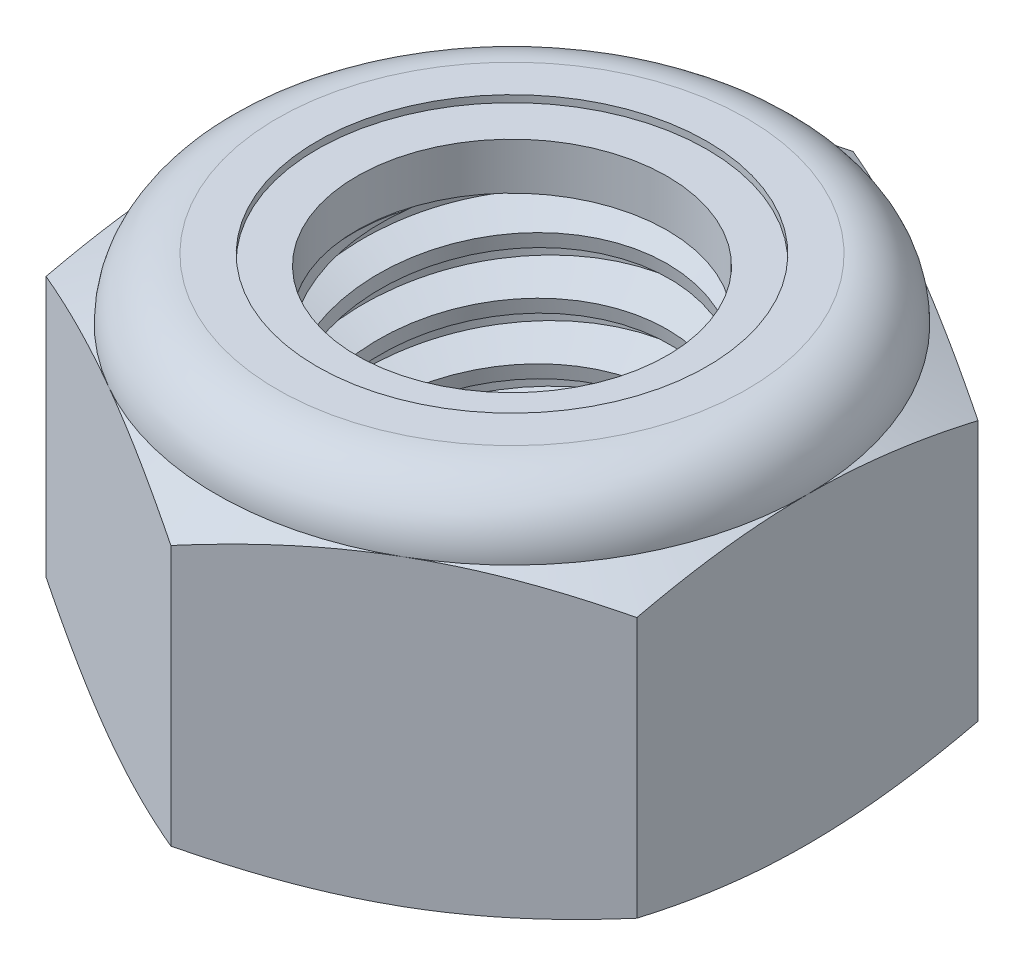
from build123d import *

# Parameters (mm, degrees)
EXTRUDE1_DEPTH      = 8
SKETCH2_W           = 4
SKETCH2_H           = 8
LPATTERN1_COUNT     = 6
LPATTERN1_PITCH     = 1.25
LPATTERN1_COL_COUNT = 2
LPATTERN1_COL_PITCH = 1.25


with BuildPart() as part:
    # Sketch1 → Extrude1 (new body)
    with BuildSketch(Plane(origin=(0, 0, 0), x_dir=(1, 0, 0), z_dir=(0, 1, 0))):
        Polygon((0, 7.505553499), (-6.5, 3.75277675), (-6.5, -3.75277675), (0, -7.505553499), (6.5, -3.75277675), (6.5, 3.75277675), align=None)
    extrude(amount=EXTRUDE1_DEPTH)

    # Sketch4 → Cut-Revolve2 (revolve, cut)
    with BuildSketch(Plane(origin=(0, 0, 0), x_dir=(0, 0, -1), z_dir=(1, 0, 0))):
        Polygon((0, 8), (4, 8), (3.415953356, 7.727654577), (3.415953356, 0.272345423), (4, 0), (0, 0), align=None)
    revolve(axis=Axis((0, 8, 0), (0, 1, 0)), mode=Mode.SUBTRACT)


with BuildPart() as body_2:
    # Sketch2 → Revolve1 (revolve)
    with BuildSketch(Plane(origin=(0, 0, 0), x_dir=(0, 0, -1), z_dir=(1, 0, 0))):
        with Locations((2, 4)):
            Rectangle(SKETCH2_W, SKETCH2_H)
    revolve(axis=Axis((0, -4, 0), (0, 1, 0)))

    # Sketch3 → Cut-Revolve1 (revolve, cut)
    with BuildSketch(Plane(origin=(0, 0, 0), x_dir=(0, 0, -1), z_dir=(1, 0, 0))):
        Polygon((4.024121388, 7.84562312), (4.1929711, 6.764984958), (3.464196131, 7.046478487), (3.415953356, 7.355232247), align=None)
    cut_revolve1 = revolve(axis=Axis((0, 8, 0.208852549), (0, -0.988012034, -0.15437688)), mode=Mode.SUBTRACT)

    # LPattern1: Cut-Revolve1 ×6
    with Locations(*[(0, -i * LPATTERN1_PITCH, 0) for i in range(1, LPATTERN1_COUNT)]):
        add(cut_revolve1, mode=Mode.SUBTRACT)

    # LPattern1 col: Cut-Revolve1 ×2
    with Locations(*[(0, i * LPATTERN1_COL_PITCH, 0) for i in range(1, LPATTERN1_COL_COUNT)]):
        add(cut_revolve1, mode=Mode.SUBTRACT)


with BuildPart() as part_1:
    add(part.part)

    # Combine1: cut body 2
    add(body_2.part, mode=Mode.SUBTRACT)

    # Sketch5 → Cut-Revolve3 (revolve, cut)
    with BuildSketch(Plane(origin=(0, 0, 0), x_dir=(0, 0, -1), z_dir=(1, 0, 0))):
        with BuildLine():
            Line((0, 0), (6.5, 0))
            Line((6.5, 0), (7.505553499, 0.468897297))
            Line((7.505553499, 0.468897297), (7.505553499, 6.197769369))
            Line((7.505553499, 6.197769369), (6.5, 6.666666667))
            ThreePointArc((6.5, 6.666666667), (6.109475708, 7.609475708), (5.166666667, 8))
            Line((5.166666667, 8), (5.166666667, 9.27))
            Line((5.166666667, 9.27), (8.775553499, 9.27))
            Line((8.775553499, 9.27), (8.775553499, -1.27))
            Line((8.775553499, -1.27), (0, -1.27))
            Line((0, -1.27), (0, 0))
        make_face()
    revolve(axis=Axis((0, 0, 0), (0, 1, 0)), mode=Mode.SUBTRACT)

    # Sketch6 → Cut-Revolve4 (revolve, cut)
    with BuildSketch(Plane(origin=(0, 0, 0), x_dir=(0, 0, -1), z_dir=(1, 0, 0))):
        with BuildLine():
            Line((0, 6.666666667), (6.3476, 6.666666667))
            ThreePointArc((6.3476, 6.666666667), (6.001712635, 7.501712635), (5.166666667, 7.8476))
            Line((5.166666667, 7.8476), (4.291310011, 7.8476))
            Line((4.291310011, 7.8476), (4.291310011, 9.27))
            Line((4.291310011, 9.27), (0, 9.27))
            Line((0, 9.27), (0, 6.666666667))
        make_face()
    revolve(axis=Axis((0, 9.27, 0), (0, 1, 0)), mode=Mode.SUBTRACT)


with BuildPart() as body_2_2:
    # Sketch7 → Revolve2 (revolve)
    with BuildSketch(Plane(origin=(0, 0, 0), x_dir=(0, 0, -1), z_dir=(1, 0, 0))):
        with BuildLine():
            Line((3.415953356, 6.742866667), (6.268768884, 6.742866667))
            ThreePointArc((6.268768884, 6.742866667), (5.920409016, 7.474322663), (5.166666667, 7.7714))
            Line((5.166666667, 7.7714), (3.415953356, 7.7714))
            Line((3.415953356, 7.7714), (3.415953356, 6.742866667))
        make_face()
    revolve(axis=Axis((0, 6.742866667, 0), (0, 1, 0)))


solid = Compound([part_1.part, body_2_2.part])
